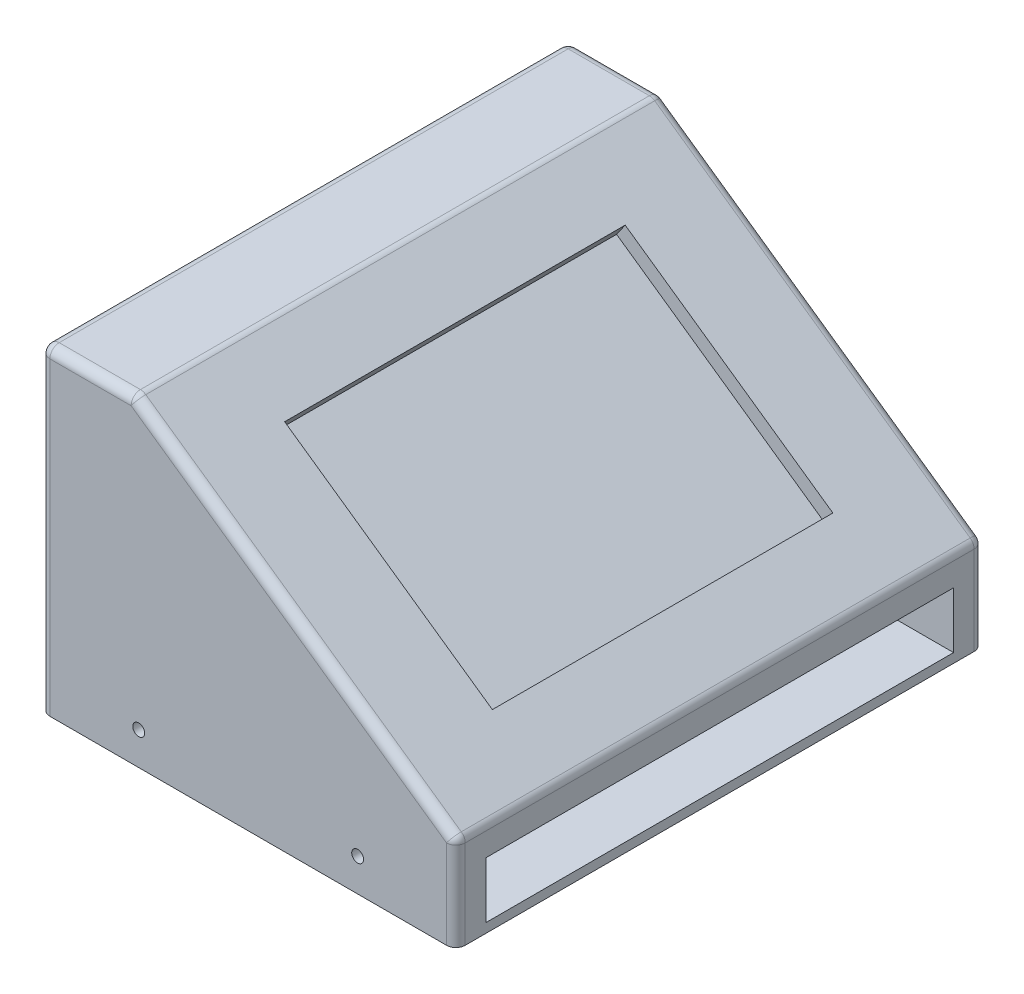
from build123d import *

# Parameters (mm, degrees)
SKETCH1_W           = 50
SKETCH1_H           = 170.451051634
BOSS_EXTRUDE1_DEPTH = 282
CUT_EXTRUDE1_DEPTH  = 8
SKETCH5_R           = 3.175
CUT_EXTRUDE3_DEPTH  = 7.7
SKETCH6_R           = 3.175
CUT_EXTRUDE4_DEPTH  = 7.7
FILLET4_R           = 5
SKETCH7_W           = 250
SKETCH7_H           = 30
CUT_EXTRUDE6_DEPTH  = 150
CUT_EXTRUDE7_DEPTH  = 20
FILLET5_R           = 10
FILLET6_R           = 5


with BuildPart() as part:
    # Sketch1 → Boss-Extrude1 (new body)
    with BuildSketch(Plane.XY):
        with Locations((-197.021929301, 35.225525817)):
            Rectangle(SKETCH1_W, SKETCH1_H)
        Polygon((0, -50), (0, 0), (-172.021929301, 120.451051634), (-172.021929301, -50), align=None)
    extrude(amount=BOSS_EXTRUDE1_DEPTH)

    # Sketch3 → Cut-Extrude1 (cut)
    with BuildSketch(Plane(origin=(0, 0, 0), x_dir=(0.819152044, -0.573576436, 0), z_dir=(0.573576436, 0.819152044, 0))):
        Polygon((-37.234042553, -232), (-172.765957447, -50), (-172.765957447, -232), align=None)
        Polygon((-37.234042553, -50), (-172.765957447, -50), (-37.234042553, -232), align=None)
    extrude(amount=-CUT_EXTRUDE1_DEPTH, mode=Mode.SUBTRACT)

    # Sketch5 → Cut-Extrude3 (cut)
    with BuildSketch(Plane.XY.offset(282)):
        with Locations((-52.5, -32.5)):
            Circle(SKETCH5_R)
        with Locations((-169.521929301, -32.5)):
            Circle(SKETCH5_R)
    extrude(amount=-CUT_EXTRUDE3_DEPTH, mode=Mode.SUBTRACT)

    # Sketch6 → Cut-Extrude4 (cut)
    with BuildSketch(Plane(origin=(0, 0, 0), x_dir=(-1, 0, 0), z_dir=(0, 0, -1))):
        with Locations((169.521929301, -32.5)):
            Circle(SKETCH6_R)
        with Locations((52.5, -32.5)):
            Circle(SKETCH6_R)
    extrude(amount=-CUT_EXTRUDE4_DEPTH, mode=Mode.SUBTRACT)

    # Fillet4
    fillet4_edges = [part.edges().sort_by_distance(p)[0] for p in [
        (-222.021929301, 35.225525817, 282),
        (-172.021929301, 120.451051634, 141),
        (0, 0, 141),
        (-222.021929301, 120.451051634, 141),
        (0, -25, 282),
        (-86.01096465, 60.225525817, 282),
        (-197.021929301, 120.451051634, 282),
        (-86.01096465, 60.225525817, 0),
        (0, -25, 0),
        (-222.021929301, 35.225525817, 0),
        (-197.021929301, 120.451051634, 0),
    ]]
    fillet(fillet4_edges, radius=FILLET4_R)

    # Sketch7 → Cut-Extrude6 (cut)
    with BuildSketch(Plane(origin=(0, 0, 0), x_dir=(0, 0, -1), z_dir=(1, 0, 0))):
        with Locations((-141, -30)):
            Rectangle(SKETCH7_W, SKETCH7_H)
    extrude(amount=-CUT_EXTRUDE6_DEPTH, mode=Mode.SUBTRACT)

    # Sketch9 → Cut-Extrude7 (cut)
    with BuildSketch(Plane(origin=(0, 0, 0), x_dir=(-1, 0, 0), z_dir=(0, 0, -1))):
        Polygon((200.305363971, 54.801104583), (102.007118657, -14.028067779), (70.460414657, 31.025294657), (168.758659972, 99.854467019), align=None)
    extrude(amount=-CUT_EXTRUDE7_DEPTH, mode=Mode.SUBTRACT)

    # Fillet5
    fillet5_edges = [part.edges().sort_by_distance(p)[0] for p in [
        (-200.305363971, 54.801104583, 10),
        (-102.007118657, -14.028067779, 10),
        (-70.460414657, 31.025294657, 10),
        (-168.758659972, 99.854467019, 10),
    ]]
    fillet(fillet5_edges, radius=FILLET5_R)

    # Fillet6
    fillet6_edges = [part.edges().sort_by_distance(p)[0] for p in [
        (-86.233766657, 8.498613439, 20),
        (-119.609537315, 65.439880838, 20),
        (-151.156241314, 20.386518402, 20),
        (-184.532011972, 77.327785801, 20),
        (-196.226156695, 55.520378886, 20),
        (-168.039385669, 95.775259743, 20),
        (-102.726392959, -9.948860503, 20),
        (-74.539621934, 30.306020354, 20),
    ]]
    fillet(fillet6_edges, radius=FILLET6_R)


solid = part.part
